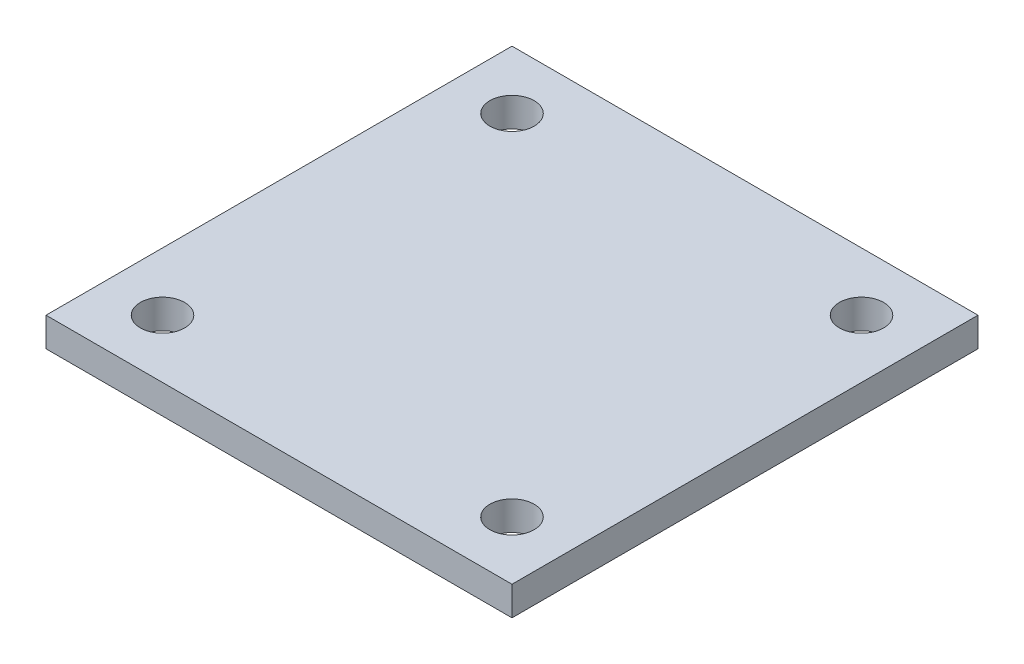
from build123d import *

# Parameters (mm, degrees)
SKETCH1_W           = 101.6
SKETCH1_H           = 101.6
BOSS_EXTRUDE1_DEPTH = 6.35
SKETCH2_R           = 4.826
CUT_EXTRUDE1_DEPTH  = 6.35


with BuildPart() as part:
    # Sketch1 → Boss-Extrude1 (new body)
    with BuildSketch(Plane(origin=(0, 0, 0), x_dir=(1, 0, 0), z_dir=(0, 1, 0))):
        Rectangle(SKETCH1_W, SKETCH1_H)
    extrude(amount=BOSS_EXTRUDE1_DEPTH)

    # Sketch2 → Cut-Extrude1 (cut)
    with BuildSketch(Plane(origin=(0, 6.35, 0), x_dir=(1, 0, 0), z_dir=(0, 1, 0))):
        with Locations((-38.1, 38.1)):
            Circle(SKETCH2_R)
        with Locations((38.1, 38.1)):
            Circle(SKETCH2_R)
        with Locations((38.1, -38.1)):
            Circle(SKETCH2_R)
        with Locations((-38.1, -38.1)):
            Circle(SKETCH2_R)
    extrude(amount=-CUT_EXTRUDE1_DEPTH, mode=Mode.SUBTRACT)


solid = part.part
